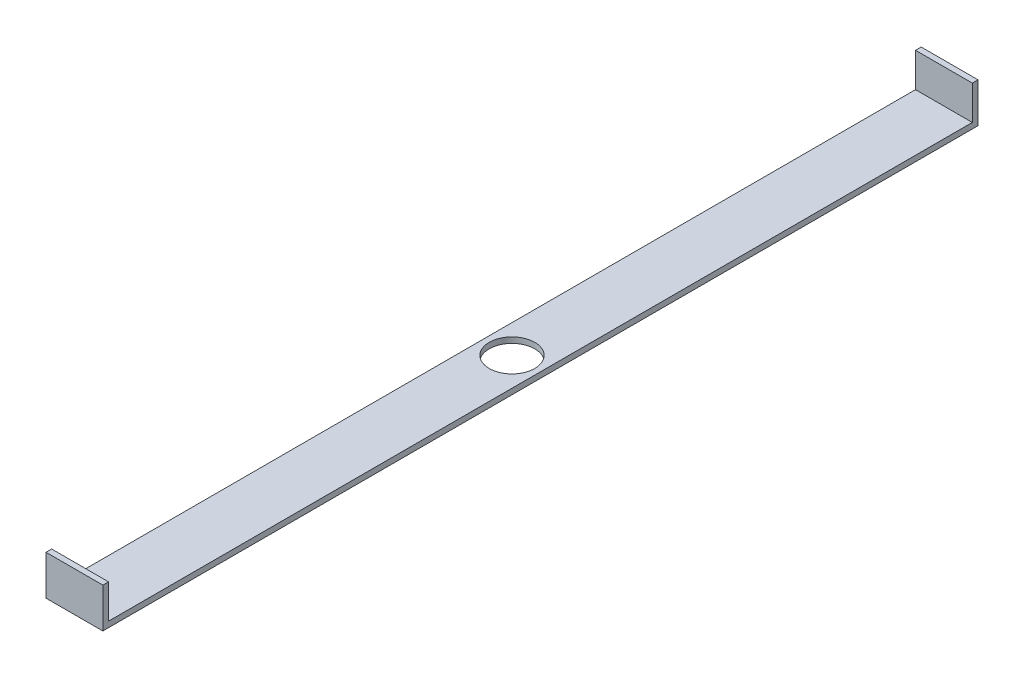
from build123d import *

# Parameters (mm, degrees)
SKETCH2_W           = 50
SKETCH2_H           = 5
BOSS_EXTRUDE1_DEPTH = 770
SKETCH3_W           = 50
SKETCH3_H           = 5
BOSS_EXTRUDE2_DEPTH = 30
SKETCH4_R           = 20
CUT_EXTRUDE1_DEPTH  = 30


with BuildPart() as part:
    # Sketch2 → Boss-Extrude1 (new body)
    with BuildSketch(Plane.XY):
        with Locations((25, -2.5)):
            Rectangle(SKETCH2_W, SKETCH2_H)
    extrude(amount=BOSS_EXTRUDE1_DEPTH)

    # Sketch3 → Boss-Extrude2 (add)
    with BuildSketch(Plane(origin=(0, 0, 0), x_dir=(1, 0, 0), z_dir=(0, 1, 0))):
        with Locations((25, -767.5)):
            Rectangle(SKETCH3_W, SKETCH3_H)
        with Locations((25, -2.5)):
            Rectangle(SKETCH3_W, SKETCH3_H)
    extrude(amount=BOSS_EXTRUDE2_DEPTH)

    # Sketch4 → Cut-Extrude1 (cut)
    with BuildSketch(Plane(origin=(0, 0, 0), x_dir=(1, 0, 0), z_dir=(0, 1, 0))):
        with Locations((25, -385)):
            Circle(SKETCH4_R)
    extrude(amount=-CUT_EXTRUDE1_DEPTH, mode=Mode.SUBTRACT)


solid = part.part
